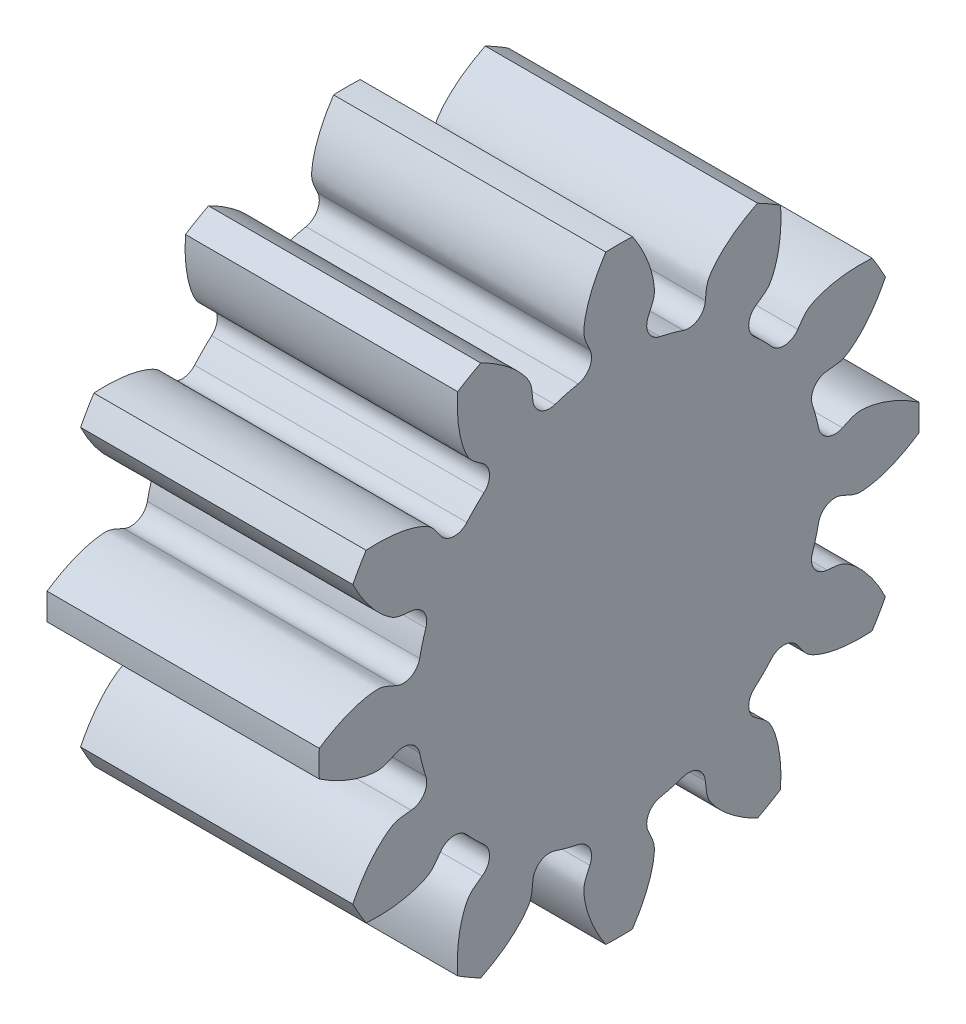
from build123d import *

# Parameters (mm, degrees)
EXTRUDE1_DEPTH      = 3.175
EXTRUDE1_DEPTH_BACK = 3.175


with BuildPart() as part:
    # Sketch1 → Extrude1 (new body, two sides)
    with BuildSketch(Plane(origin=(0, 0, 0), x_dir=(0, 0, -1), z_dir=(1, 0, 0))) as extrude1_sk:
        with BuildLine():
            ThreePointArc((-0.310347402, -6.993116937), (0, -7), (0.310347402, -6.993116937))
            add(Edge.make_bspline(
                [(0.310347402, -6.993116937), (0.332454088, -6.960100751), (0.397086112, -6.860495296), (0.507596749, -6.672467535), (0.626125065, -6.431893946), (0.720246921, -6.186920197), (0.779000049, -5.979736241), (0.809954136, -5.81518889), (0.821047695, -5.703074132), (0.822305692, -5.636998123), (0.821610044, -5.605303583), (0.814736989, -5.520886657), (0.783208617, -5.41000535), (0.683474653, -5.206966814)],
                knots=[0.012881598, 0.012881598, 0.012881598, 0.012881598, 0.092763794, 0.252528185, 0.452803648, 0.613451009, 0.736634468, 0.825277424, 0.882733012, 0.901221839, 0.913572897, 0.922587449, 0.997832853, 0.997832853, 0.997832853, 0.997832853], degree=3, weights=[1, 1, 1, 1, 1, 1, 1, 1, 1, 1, 1, 1, 1, 1]))
            ThreePointArc((0.683474653, -5.206966814), (0.6833523, -4.863322946), (0.955104633, -4.652985616))
            ThreePointArc((0.955104633, -4.652985616), (1.229390464, -4.588147675), (1.499347932, -4.507156063))
            ThreePointArc((1.499347932, -4.507156063), (1.839861021, -4.553437368), (2.011576994, -4.851102864))
            add(Edge.make_bspline(
                [(2.011576994, -4.851102864), (2.026724117, -5.076806376), (2.054860398, -5.188596591), (2.091116621, -5.265140321), (2.106361443, -5.292936422), (2.140488904, -5.349530925), (2.206153588, -5.441078375), (2.315234289, -5.568103517), (2.469707968, -5.718153522), (2.67370676, -5.883246084), (2.896642088, -6.032324766), (3.086360987, -6.139906265), (3.19213669, -6.193851107), (3.227789734, -6.21139062)],
                knots=[0.002100409, 0.002100409, 0.002100409, 0.002100409, 0.077349591, 0.086364597, 0.098716275, 0.11720603, 0.174664504, 0.263311911, 0.386501556, 0.547156985, 0.747442506, 0.90721492, 0.987101128, 0.987101128, 0.987101128, 0.987101128], degree=3, weights=[1, 1, 1, 1, 1, 1, 1, 1, 1, 1, 1, 1, 1, 1]))
            ThreePointArc((3.227789734, -6.21139062), (3.5, -6.062177826), (3.765327202, -5.901043218))
            add(Edge.make_bspline(
                [(3.765327202, -5.901043218), (3.767964061, -5.861397019), (3.774134309, -5.742820152), (3.775825447, -5.524728017), (3.758187185, -5.257121019), (3.717212229, -4.997906601), (3.664501952, -4.789103468), (3.609035303, -4.631124239), (3.562585227, -4.52848323), (3.530636681, -4.47063073), (3.514186962, -4.443530277), (3.466026259, -4.373859602), (3.383281234, -4.293597759), (3.195389819, -4.167628211)],
                knots=[0.012881598, 0.012881598, 0.012881598, 0.012881598, 0.092763794, 0.252528185, 0.452803648, 0.613451009, 0.736634468, 0.825277424, 0.882733012, 0.901221839, 0.913572897, 0.922587449, 0.997832853, 0.997832853, 0.997832853, 0.997832853], degree=3, weights=[1, 1, 1, 1, 1, 1, 1, 1, 1, 1, 1, 1, 1, 1]))
            ThreePointArc((3.195389819, -4.167628211), (3.023461924, -3.870085068), (3.153637683, -3.55205143))
            ThreePointArc((3.153637683, -3.55205143), (3.358757211, -3.358757211), (3.55205143, -3.153637683))
            ThreePointArc((3.55205143, -3.153637683), (3.870085068, -3.023461924), (4.167628211, -3.195389819))
            add(Edge.make_bspline(
                [(4.167628211, -3.195389819), (4.293597759, -3.383281234), (4.373859602, -3.466026259), (4.443530277, -3.514186962), (4.47063073, -3.530636681), (4.52848323, -3.562585227), (4.631124239, -3.609035303), (4.789103468, -3.664501952), (4.997906601, -3.717212229), (5.257121019, -3.758187185), (5.524728017, -3.775825447), (5.742820152, -3.774134309), (5.861397019, -3.767964061), (5.901043218, -3.765327202)],
                knots=[0.002100409, 0.002100409, 0.002100409, 0.002100409, 0.077349591, 0.086364597, 0.098716275, 0.11720603, 0.174664504, 0.263311911, 0.386501556, 0.547156985, 0.747442506, 0.90721492, 0.987101128, 0.987101128, 0.987101128, 0.987101128], degree=3, weights=[1, 1, 1, 1, 1, 1, 1, 1, 1, 1, 1, 1, 1, 1]))
            ThreePointArc((5.901043218, -3.765327202), (6.062177826, -3.5), (6.21139062, -3.227789734))
            add(Edge.make_bspline(
                [(6.21139062, -3.227789734), (6.193851107, -3.19213669), (6.139906265, -3.086360987), (6.032324766, -2.896642088), (5.883246084, -2.67370676), (5.718153522, -2.469707968), (5.568103517, -2.315234289), (5.441078375, -2.206153588), (5.349530925, -2.140488904), (5.292936422, -2.106361443), (5.265140321, -2.091116621), (5.188596591, -2.054860398), (5.076806376, -2.026724117), (4.851102864, -2.011576994)],
                knots=[0.012881598, 0.012881598, 0.012881598, 0.012881598, 0.092763794, 0.252528185, 0.452803648, 0.613451009, 0.736634468, 0.825277424, 0.882733012, 0.901221839, 0.913572897, 0.922587449, 0.997832853, 0.997832853, 0.997832853, 0.997832853], degree=3, weights=[1, 1, 1, 1, 1, 1, 1, 1, 1, 1, 1, 1, 1, 1]))
            ThreePointArc((4.851102864, -2.011576994), (4.553437368, -1.839861021), (4.507156063, -1.499347932))
            ThreePointArc((4.507156063, -1.499347932), (4.588147675, -1.229390464), (4.652985616, -0.955104633))
            ThreePointArc((4.652985616, -0.955104633), (4.863322946, -0.6833523), (5.206966814, -0.683474653))
            add(Edge.make_bspline(
                [(5.206966814, -0.683474653), (5.41000535, -0.783208617), (5.520886657, -0.814736989), (5.605303583, -0.821610044), (5.636998123, -0.822305692), (5.703074132, -0.821047695), (5.81518889, -0.809954136), (5.979736241, -0.779000049), (6.186920197, -0.720246921), (6.431893946, -0.626125065), (6.672467535, -0.507596749), (6.860495296, -0.397086112), (6.960100751, -0.332454088), (6.993116937, -0.310347402)],
                knots=[0.002100409, 0.002100409, 0.002100409, 0.002100409, 0.077349591, 0.086364597, 0.098716275, 0.11720603, 0.174664504, 0.263311911, 0.386501556, 0.547156985, 0.747442506, 0.90721492, 0.987101128, 0.987101128, 0.987101128, 0.987101128], degree=3, weights=[1, 1, 1, 1, 1, 1, 1, 1, 1, 1, 1, 1, 1, 1]))
            ThreePointArc((6.993116937, -0.310347402), (7, 0), (6.993116937, 0.310347402))
            add(Edge.make_bspline(
                [(6.993116937, 0.310347402), (6.960100751, 0.332454088), (6.860495296, 0.397086112), (6.672467535, 0.507596749), (6.431893946, 0.626125065), (6.186920197, 0.720246921), (5.979736241, 0.779000049), (5.81518889, 0.809954136), (5.703074132, 0.821047695), (5.636998123, 0.822305692), (5.605303583, 0.821610044), (5.520886657, 0.814736989), (5.41000535, 0.783208617), (5.206966814, 0.683474653)],
                knots=[0.012881598, 0.012881598, 0.012881598, 0.012881598, 0.092763794, 0.252528185, 0.452803648, 0.613451009, 0.736634468, 0.825277424, 0.882733012, 0.901221839, 0.913572897, 0.922587449, 0.997832853, 0.997832853, 0.997832853, 0.997832853], degree=3, weights=[1, 1, 1, 1, 1, 1, 1, 1, 1, 1, 1, 1, 1, 1]))
            ThreePointArc((5.206966814, 0.683474653), (4.863322946, 0.6833523), (4.652985616, 0.955104633))
            ThreePointArc((4.652985616, 0.955104633), (4.588147675, 1.229390464), (4.507156063, 1.499347932))
            ThreePointArc((4.507156063, 1.499347932), (4.553437368, 1.839861021), (4.851102864, 2.011576994))
            add(Edge.make_bspline(
                [(4.851102864, 2.011576994), (5.076806376, 2.026724117), (5.188596591, 2.054860398), (5.265140321, 2.091116621), (5.292936422, 2.106361443), (5.349530925, 2.140488904), (5.441078375, 2.206153588), (5.568103517, 2.315234289), (5.718153522, 2.469707968), (5.883246084, 2.67370676), (6.032324766, 2.896642088), (6.139906265, 3.086360987), (6.193851107, 3.19213669), (6.21139062, 3.227789734)],
                knots=[0.002100409, 0.002100409, 0.002100409, 0.002100409, 0.077349591, 0.086364597, 0.098716275, 0.11720603, 0.174664504, 0.263311911, 0.386501556, 0.547156985, 0.747442506, 0.90721492, 0.987101128, 0.987101128, 0.987101128, 0.987101128], degree=3, weights=[1, 1, 1, 1, 1, 1, 1, 1, 1, 1, 1, 1, 1, 1]))
            ThreePointArc((6.21139062, 3.227789734), (6.062177826, 3.5), (5.901043218, 3.765327202))
            add(Edge.make_bspline(
                [(5.901043218, 3.765327202), (5.861397019, 3.767964061), (5.742820152, 3.774134309), (5.524728017, 3.775825447), (5.257121019, 3.758187185), (4.997906601, 3.717212229), (4.789103468, 3.664501952), (4.631124239, 3.609035303), (4.52848323, 3.562585227), (4.47063073, 3.530636681), (4.443530277, 3.514186962), (4.373859602, 3.466026259), (4.293597759, 3.383281234), (4.167628211, 3.195389819)],
                knots=[0.012881598, 0.012881598, 0.012881598, 0.012881598, 0.092763794, 0.252528185, 0.452803648, 0.613451009, 0.736634468, 0.825277424, 0.882733012, 0.901221839, 0.913572897, 0.922587449, 0.997832853, 0.997832853, 0.997832853, 0.997832853], degree=3, weights=[1, 1, 1, 1, 1, 1, 1, 1, 1, 1, 1, 1, 1, 1]))
            ThreePointArc((4.167628211, 3.195389819), (3.870085068, 3.023461924), (3.55205143, 3.153637683))
            ThreePointArc((3.55205143, 3.153637683), (3.358757211, 3.358757211), (3.153637683, 3.55205143))
            ThreePointArc((3.153637683, 3.55205143), (3.023461924, 3.870085068), (3.195389819, 4.167628211))
            add(Edge.make_bspline(
                [(3.195389819, 4.167628211), (3.383281234, 4.293597759), (3.466026259, 4.373859602), (3.514186962, 4.443530277), (3.530636681, 4.47063073), (3.562585227, 4.52848323), (3.609035303, 4.631124239), (3.664501952, 4.789103468), (3.717212229, 4.997906601), (3.758187185, 5.257121019), (3.775825447, 5.524728017), (3.774134309, 5.742820152), (3.767964061, 5.861397019), (3.765327202, 5.901043218)],
                knots=[0.002100409, 0.002100409, 0.002100409, 0.002100409, 0.077349591, 0.086364597, 0.098716275, 0.11720603, 0.174664504, 0.263311911, 0.386501556, 0.547156985, 0.747442506, 0.90721492, 0.987101128, 0.987101128, 0.987101128, 0.987101128], degree=3, weights=[1, 1, 1, 1, 1, 1, 1, 1, 1, 1, 1, 1, 1, 1]))
            ThreePointArc((3.765327202, 5.901043218), (3.5, 6.062177826), (3.227789734, 6.21139062))
            add(Edge.make_bspline(
                [(3.227789734, 6.21139062), (3.19213669, 6.193851107), (3.086360987, 6.139906265), (2.896642088, 6.032324766), (2.67370676, 5.883246084), (2.469707968, 5.718153522), (2.315234289, 5.568103517), (2.206153588, 5.441078375), (2.140488904, 5.349530925), (2.106361443, 5.292936422), (2.091116621, 5.265140321), (2.054860398, 5.188596591), (2.026724117, 5.076806376), (2.011576994, 4.851102864)],
                knots=[0.012881598, 0.012881598, 0.012881598, 0.012881598, 0.092763794, 0.252528185, 0.452803648, 0.613451009, 0.736634468, 0.825277424, 0.882733012, 0.901221839, 0.913572897, 0.922587449, 0.997832853, 0.997832853, 0.997832853, 0.997832853], degree=3, weights=[1, 1, 1, 1, 1, 1, 1, 1, 1, 1, 1, 1, 1, 1]))
            ThreePointArc((2.011576994, 4.851102864), (1.839861021, 4.553437368), (1.499347932, 4.507156063))
            ThreePointArc((1.499347932, 4.507156063), (1.229390464, 4.588147675), (0.955104633, 4.652985616))
            ThreePointArc((0.955104633, 4.652985616), (0.6833523, 4.863322946), (0.683474653, 5.206966814))
            add(Edge.make_bspline(
                [(0.683474653, 5.206966814), (0.783208617, 5.41000535), (0.814736989, 5.520886657), (0.821610044, 5.605303583), (0.822305692, 5.636998123), (0.821047695, 5.703074132), (0.809954136, 5.81518889), (0.779000049, 5.979736241), (0.720246921, 6.186920197), (0.626125065, 6.431893946), (0.507596749, 6.672467535), (0.397086112, 6.860495296), (0.332454088, 6.960100751), (0.310347402, 6.993116937)],
                knots=[0.002100409, 0.002100409, 0.002100409, 0.002100409, 0.077349591, 0.086364597, 0.098716275, 0.11720603, 0.174664504, 0.263311911, 0.386501556, 0.547156985, 0.747442506, 0.90721492, 0.987101128, 0.987101128, 0.987101128, 0.987101128], degree=3, weights=[1, 1, 1, 1, 1, 1, 1, 1, 1, 1, 1, 1, 1, 1]))
            ThreePointArc((0.310347402, 6.993116937), (0, 7), (-0.310347402, 6.993116937))
            add(Edge.make_bspline(
                [(-0.310347402, 6.993116937), (-0.332454088, 6.960100751), (-0.397086112, 6.860495296), (-0.507596749, 6.672467535), (-0.626125065, 6.431893946), (-0.720246921, 6.186920197), (-0.779000049, 5.979736241), (-0.809954136, 5.81518889), (-0.821047695, 5.703074132), (-0.822305692, 5.636998123), (-0.821610044, 5.605303583), (-0.814736989, 5.520886657), (-0.783208617, 5.41000535), (-0.683474653, 5.206966814)],
                knots=[0.012881598, 0.012881598, 0.012881598, 0.012881598, 0.092763794, 0.252528185, 0.452803648, 0.613451009, 0.736634468, 0.825277424, 0.882733012, 0.901221839, 0.913572897, 0.922587449, 0.997832853, 0.997832853, 0.997832853, 0.997832853], degree=3, weights=[1, 1, 1, 1, 1, 1, 1, 1, 1, 1, 1, 1, 1, 1]))
            ThreePointArc((-0.683474653, 5.206966814), (-0.6833523, 4.863322946), (-0.955104633, 4.652985616))
            ThreePointArc((-0.955104633, 4.652985616), (-1.229390464, 4.588147675), (-1.499347932, 4.507156063))
            ThreePointArc((-1.499347932, 4.507156063), (-1.839861021, 4.553437368), (-2.011576994, 4.851102864))
            add(Edge.make_bspline(
                [(-2.011576994, 4.851102864), (-2.026724117, 5.076806376), (-2.054860398, 5.188596591), (-2.091116621, 5.265140321), (-2.106361443, 5.292936422), (-2.140488904, 5.349530925), (-2.206153588, 5.441078375), (-2.315234289, 5.568103517), (-2.469707968, 5.718153522), (-2.67370676, 5.883246084), (-2.896642088, 6.032324766), (-3.086360987, 6.139906265), (-3.19213669, 6.193851107), (-3.227789734, 6.21139062)],
                knots=[0.002100409, 0.002100409, 0.002100409, 0.002100409, 0.077349591, 0.086364597, 0.098716275, 0.11720603, 0.174664504, 0.263311911, 0.386501556, 0.547156985, 0.747442506, 0.90721492, 0.987101128, 0.987101128, 0.987101128, 0.987101128], degree=3, weights=[1, 1, 1, 1, 1, 1, 1, 1, 1, 1, 1, 1, 1, 1]))
            ThreePointArc((-3.227789734, 6.21139062), (-3.5, 6.062177826), (-3.765327202, 5.901043218))
            add(Edge.make_bspline(
                [(-3.765327202, 5.901043218), (-3.767964061, 5.861397019), (-3.774134309, 5.742820152), (-3.775825447, 5.524728017), (-3.758187185, 5.257121019), (-3.717212229, 4.997906601), (-3.664501952, 4.789103468), (-3.609035303, 4.631124239), (-3.562585227, 4.52848323), (-3.530636681, 4.47063073), (-3.514186962, 4.443530277), (-3.466026259, 4.373859602), (-3.383281234, 4.293597759), (-3.195389819, 4.167628211)],
                knots=[0.012881598, 0.012881598, 0.012881598, 0.012881598, 0.092763794, 0.252528185, 0.452803648, 0.613451009, 0.736634468, 0.825277424, 0.882733012, 0.901221839, 0.913572897, 0.922587449, 0.997832853, 0.997832853, 0.997832853, 0.997832853], degree=3, weights=[1, 1, 1, 1, 1, 1, 1, 1, 1, 1, 1, 1, 1, 1]))
            ThreePointArc((-3.195389819, 4.167628211), (-3.023461924, 3.870085068), (-3.153637683, 3.55205143))
            ThreePointArc((-3.153637683, 3.55205143), (-3.358757211, 3.358757211), (-3.55205143, 3.153637683))
            ThreePointArc((-3.55205143, 3.153637683), (-3.870085068, 3.023461924), (-4.167628211, 3.195389819))
            add(Edge.make_bspline(
                [(-4.167628211, 3.195389819), (-4.293597759, 3.383281234), (-4.373859602, 3.466026259), (-4.443530277, 3.514186962), (-4.47063073, 3.530636681), (-4.52848323, 3.562585227), (-4.631124239, 3.609035303), (-4.789103468, 3.664501952), (-4.997906601, 3.717212229), (-5.257121019, 3.758187185), (-5.524728017, 3.775825447), (-5.742820152, 3.774134309), (-5.861397019, 3.767964061), (-5.901043218, 3.765327202)],
                knots=[0.002100409, 0.002100409, 0.002100409, 0.002100409, 0.077349591, 0.086364597, 0.098716275, 0.11720603, 0.174664504, 0.263311911, 0.386501556, 0.547156985, 0.747442506, 0.90721492, 0.987101128, 0.987101128, 0.987101128, 0.987101128], degree=3, weights=[1, 1, 1, 1, 1, 1, 1, 1, 1, 1, 1, 1, 1, 1]))
            ThreePointArc((-5.901043218, 3.765327202), (-6.062177826, 3.5), (-6.21139062, 3.227789734))
            add(Edge.make_bspline(
                [(-6.21139062, 3.227789734), (-6.193851107, 3.19213669), (-6.139906265, 3.086360987), (-6.032324766, 2.896642088), (-5.883246084, 2.67370676), (-5.718153522, 2.469707968), (-5.568103517, 2.315234289), (-5.441078375, 2.206153588), (-5.349530925, 2.140488904), (-5.292936422, 2.106361443), (-5.265140321, 2.091116621), (-5.188596591, 2.054860398), (-5.076806376, 2.026724117), (-4.851102864, 2.011576994)],
                knots=[0.012881598, 0.012881598, 0.012881598, 0.012881598, 0.092763794, 0.252528185, 0.452803648, 0.613451009, 0.736634468, 0.825277424, 0.882733012, 0.901221839, 0.913572897, 0.922587449, 0.997832853, 0.997832853, 0.997832853, 0.997832853], degree=3, weights=[1, 1, 1, 1, 1, 1, 1, 1, 1, 1, 1, 1, 1, 1]))
            ThreePointArc((-4.851102864, 2.011576994), (-4.553437368, 1.839861021), (-4.507156063, 1.499347932))
            ThreePointArc((-4.507156063, 1.499347932), (-4.588147675, 1.229390464), (-4.652985616, 0.955104633))
            ThreePointArc((-4.652985616, 0.955104633), (-4.863322946, 0.6833523), (-5.206966814, 0.683474653))
            add(Edge.make_bspline(
                [(-5.206966814, 0.683474653), (-5.41000535, 0.783208617), (-5.520886657, 0.814736989), (-5.605303583, 0.821610044), (-5.636998123, 0.822305692), (-5.703074132, 0.821047695), (-5.81518889, 0.809954136), (-5.979736241, 0.779000049), (-6.186920197, 0.720246921), (-6.431893946, 0.626125065), (-6.672467535, 0.507596749), (-6.860495296, 0.397086112), (-6.960100751, 0.332454088), (-6.993116937, 0.310347402)],
                knots=[0.002100409, 0.002100409, 0.002100409, 0.002100409, 0.077349591, 0.086364597, 0.098716275, 0.11720603, 0.174664504, 0.263311911, 0.386501556, 0.547156985, 0.747442506, 0.90721492, 0.987101128, 0.987101128, 0.987101128, 0.987101128], degree=3, weights=[1, 1, 1, 1, 1, 1, 1, 1, 1, 1, 1, 1, 1, 1]))
            ThreePointArc((-6.993116937, 0.310347402), (-7, 0), (-6.993116937, -0.310347402))
            add(Edge.make_bspline(
                [(-6.993116937, -0.310347402), (-6.960100751, -0.332454088), (-6.860495296, -0.397086112), (-6.672467535, -0.507596749), (-6.431893946, -0.626125065), (-6.186920197, -0.720246921), (-5.979736241, -0.779000049), (-5.81518889, -0.809954136), (-5.703074132, -0.821047695), (-5.636998123, -0.822305692), (-5.605303583, -0.821610044), (-5.520886657, -0.814736989), (-5.41000535, -0.783208617), (-5.206966814, -0.683474653)],
                knots=[0.012881598, 0.012881598, 0.012881598, 0.012881598, 0.092763794, 0.252528185, 0.452803648, 0.613451009, 0.736634468, 0.825277424, 0.882733012, 0.901221839, 0.913572897, 0.922587449, 0.997832853, 0.997832853, 0.997832853, 0.997832853], degree=3, weights=[1, 1, 1, 1, 1, 1, 1, 1, 1, 1, 1, 1, 1, 1]))
            ThreePointArc((-5.206966814, -0.683474653), (-4.863322946, -0.6833523), (-4.652985616, -0.955104633))
            ThreePointArc((-4.652985616, -0.955104633), (-4.588147675, -1.229390464), (-4.507156063, -1.499347932))
            ThreePointArc((-4.507156063, -1.499347932), (-4.553437368, -1.839861021), (-4.851102864, -2.011576994))
            add(Edge.make_bspline(
                [(-4.851102864, -2.011576994), (-5.076806376, -2.026724117), (-5.188596591, -2.054860398), (-5.265140321, -2.091116621), (-5.292936422, -2.106361443), (-5.349530925, -2.140488904), (-5.441078375, -2.206153588), (-5.568103517, -2.315234289), (-5.718153522, -2.469707968), (-5.883246084, -2.67370676), (-6.032324766, -2.896642088), (-6.139906265, -3.086360987), (-6.193851107, -3.19213669), (-6.21139062, -3.227789734)],
                knots=[0.002100409, 0.002100409, 0.002100409, 0.002100409, 0.077349591, 0.086364597, 0.098716275, 0.11720603, 0.174664504, 0.263311911, 0.386501556, 0.547156985, 0.747442506, 0.90721492, 0.987101128, 0.987101128, 0.987101128, 0.987101128], degree=3, weights=[1, 1, 1, 1, 1, 1, 1, 1, 1, 1, 1, 1, 1, 1]))
            ThreePointArc((-6.21139062, -3.227789734), (-6.062177826, -3.5), (-5.901043218, -3.765327202))
            add(Edge.make_bspline(
                [(-5.901043218, -3.765327202), (-5.861397019, -3.767964061), (-5.742820152, -3.774134309), (-5.524728017, -3.775825447), (-5.257121019, -3.758187185), (-4.997906601, -3.717212229), (-4.789103468, -3.664501952), (-4.631124239, -3.609035303), (-4.52848323, -3.562585227), (-4.47063073, -3.530636681), (-4.443530277, -3.514186962), (-4.373859602, -3.466026259), (-4.293597759, -3.383281234), (-4.167628211, -3.195389819)],
                knots=[0.012881598, 0.012881598, 0.012881598, 0.012881598, 0.092763794, 0.252528185, 0.452803648, 0.613451009, 0.736634468, 0.825277424, 0.882733012, 0.901221839, 0.913572897, 0.922587449, 0.997832853, 0.997832853, 0.997832853, 0.997832853], degree=3, weights=[1, 1, 1, 1, 1, 1, 1, 1, 1, 1, 1, 1, 1, 1]))
            ThreePointArc((-4.167628211, -3.195389819), (-3.870085068, -3.023461924), (-3.55205143, -3.153637683))
            ThreePointArc((-3.55205143, -3.153637683), (-3.358757211, -3.358757211), (-3.153637683, -3.55205143))
            ThreePointArc((-3.153637683, -3.55205143), (-3.023461924, -3.870085068), (-3.195389819, -4.167628211))
            add(Edge.make_bspline(
                [(-3.195389819, -4.167628211), (-3.383281234, -4.293597759), (-3.466026259, -4.373859602), (-3.514186962, -4.443530277), (-3.530636681, -4.47063073), (-3.562585227, -4.52848323), (-3.609035303, -4.631124239), (-3.664501952, -4.789103468), (-3.717212229, -4.997906601), (-3.758187185, -5.257121019), (-3.775825447, -5.524728017), (-3.774134309, -5.742820152), (-3.767964061, -5.861397019), (-3.765327202, -5.901043218)],
                knots=[0.002100409, 0.002100409, 0.002100409, 0.002100409, 0.077349591, 0.086364597, 0.098716275, 0.11720603, 0.174664504, 0.263311911, 0.386501556, 0.547156985, 0.747442506, 0.90721492, 0.987101128, 0.987101128, 0.987101128, 0.987101128], degree=3, weights=[1, 1, 1, 1, 1, 1, 1, 1, 1, 1, 1, 1, 1, 1]))
            ThreePointArc((-3.765327202, -5.901043218), (-3.5, -6.062177826), (-3.227789734, -6.21139062))
            add(Edge.make_bspline(
                [(-3.227789734, -6.21139062), (-3.19213669, -6.193851107), (-3.086360987, -6.139906265), (-2.896642088, -6.032324766), (-2.67370676, -5.883246084), (-2.469707968, -5.718153522), (-2.315234289, -5.568103517), (-2.206153588, -5.441078375), (-2.140488904, -5.349530925), (-2.106361443, -5.292936422), (-2.091116621, -5.265140321), (-2.054860398, -5.188596591), (-2.026724117, -5.076806376), (-2.011576994, -4.851102864)],
                knots=[0.012881598, 0.012881598, 0.012881598, 0.012881598, 0.092763794, 0.252528185, 0.452803648, 0.613451009, 0.736634468, 0.825277424, 0.882733012, 0.901221839, 0.913572897, 0.922587449, 0.997832853, 0.997832853, 0.997832853, 0.997832853], degree=3, weights=[1, 1, 1, 1, 1, 1, 1, 1, 1, 1, 1, 1, 1, 1]))
            ThreePointArc((-2.011576994, -4.851102864), (-1.839861021, -4.553437368), (-1.499347932, -4.507156063))
            ThreePointArc((-1.499347932, -4.507156063), (-1.229390464, -4.588147675), (-0.955104633, -4.652985616))
            ThreePointArc((-0.955104633, -4.652985616), (-0.6833523, -4.863322946), (-0.683474653, -5.206966814))
            add(Edge.make_bspline(
                [(-0.683474653, -5.206966814), (-0.783208617, -5.41000535), (-0.814736989, -5.520886657), (-0.821610044, -5.605303583), (-0.822305692, -5.636998123), (-0.821047695, -5.703074132), (-0.809954136, -5.81518889), (-0.779000049, -5.979736241), (-0.720246921, -6.186920197), (-0.626125065, -6.431893946), (-0.507596749, -6.672467535), (-0.397086112, -6.860495296), (-0.332454088, -6.960100751), (-0.310347402, -6.993116937)],
                knots=[0.002100409, 0.002100409, 0.002100409, 0.002100409, 0.077349591, 0.086364597, 0.098716275, 0.11720603, 0.174664504, 0.263311911, 0.386501556, 0.547156985, 0.747442506, 0.90721492, 0.987101128, 0.987101128, 0.987101128, 0.987101128], degree=3, weights=[1, 1, 1, 1, 1, 1, 1, 1, 1, 1, 1, 1, 1, 1]))
        make_face()
    extrude(amount=EXTRUDE1_DEPTH)
    extrude(extrude1_sk.sketch, amount=-EXTRUDE1_DEPTH_BACK)


solid = part.part
